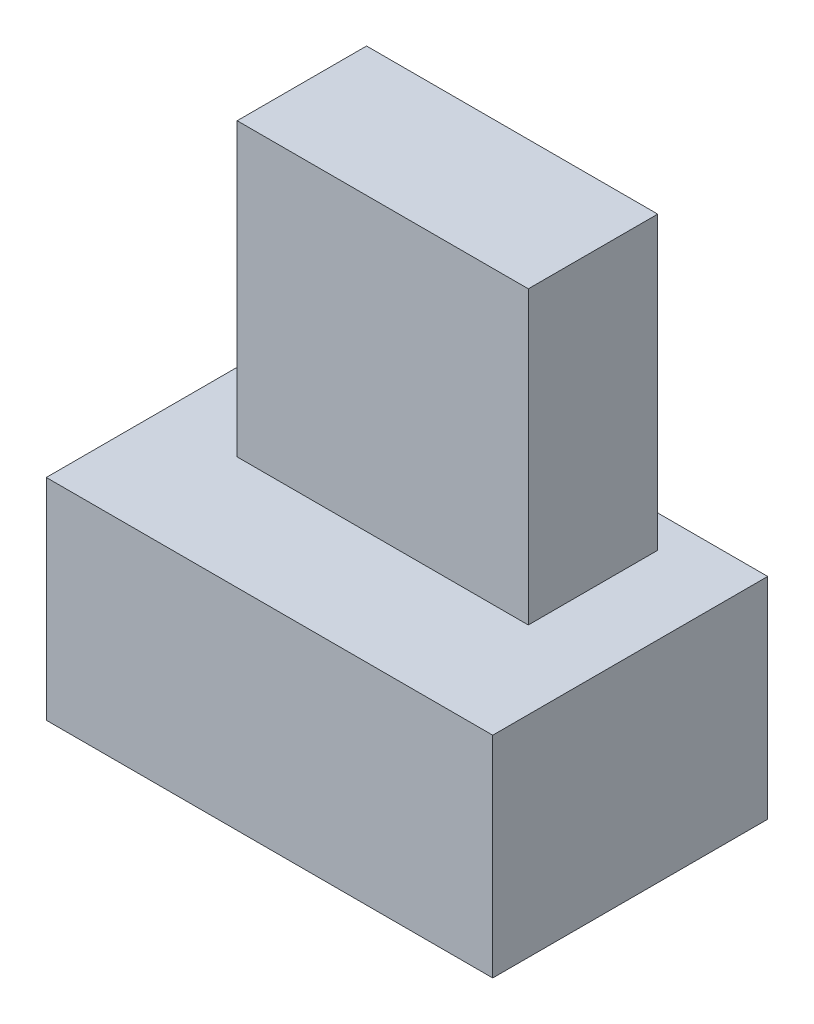
from build123d import *

# Parameters (mm, degrees)
SKETCH2_W           = 13.8
SKETCH2_H           = 8.5
BOSS_EXTRUDE1_DEPTH = 6.5
SKETCH5_W           = 9
SKETCH5_H           = 4
BOSS_EXTRUDE3_DEPTH = 9


with BuildPart() as part:
    # Sketch2 → Boss-Extrude1 (new body)
    with BuildSketch(Plane(origin=(0, 0, 0), x_dir=(1, 0, 0), z_dir=(0, 1, 0))):
        with Locations((6.9, 4.25)):
            Rectangle(SKETCH2_W, SKETCH2_H)
    extrude(amount=BOSS_EXTRUDE1_DEPTH)

    # Sketch5 → Boss-Extrude3 (add)
    with BuildSketch(Plane(origin=(0, 6.5, 0), x_dir=(-1, 0, 0), z_dir=(0, 1, 0))):
        with Locations((-6.9, -5.5)):
            Rectangle(SKETCH5_W, SKETCH5_H)
    extrude(amount=BOSS_EXTRUDE3_DEPTH)


solid = part.part
